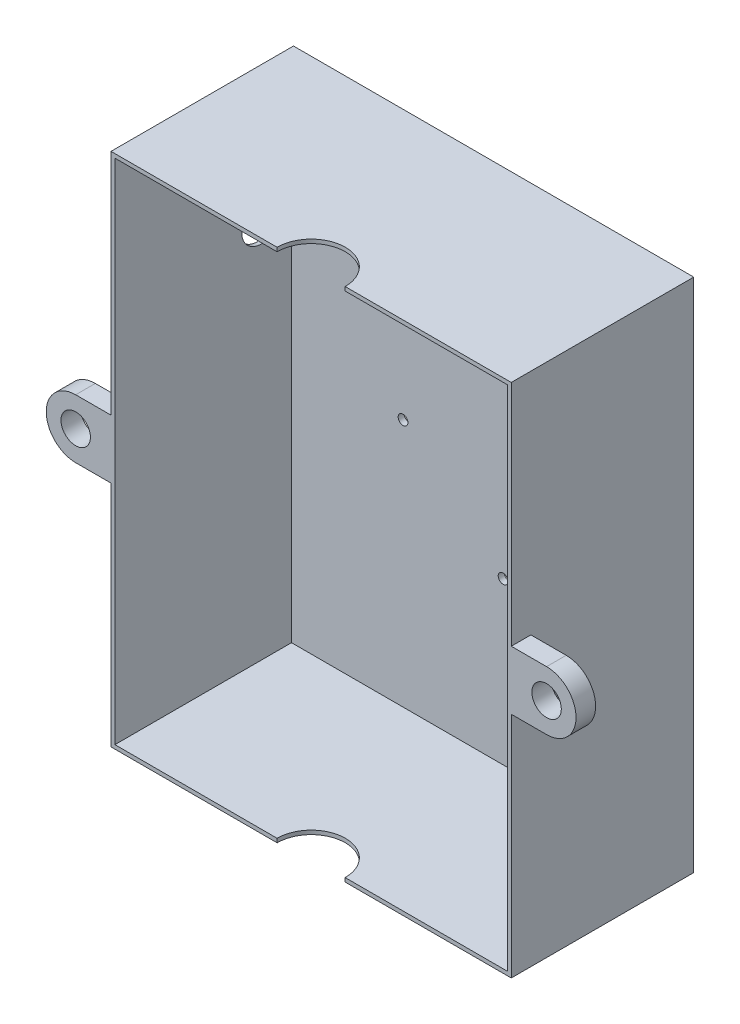
from build123d import *

# Parameters (mm, degrees)
SKETCH1_W                = 200
SKETCH1_H                = 258.87959476
BOSS_EXTRUDE1_DEPTH      = 3
SKETCH2_W                = 200
SKETCH2_H                = 258.87959476
BOSS_EXTRUDE3_DEPTH      = 90
BOSS_EXTRUDE3_DEPTH_BACK = 3
SKETCH3_R                = 2.5
CUT_EXTRUDE2_DEPTH       = 3
SKETCH4_R                = 17.332315934
CUT_EXTRUDE4_DEPTH       = 263.87959476
SKETCH5_R                = 7.5
BOSS_EXTRUDE5_DEPTH      = 10
CUT_EXTRUDE5_REACH       = 239
SKETCH6_R                = 10


with BuildPart() as part:
    # Sketch1 → Boss-Extrude1 (new body)
    with BuildSketch(Plane(origin=(0, 0, 0), x_dir=(-1, 0, 0), z_dir=(0, 0, 1))):
        with Locations((-1.649083583, 6.704740248)):
            Rectangle(SKETCH1_W, SKETCH1_H)
    extrude(amount=BOSS_EXTRUDE1_DEPTH)

    # Sketch2 → Boss-Extrude3 (add, two sides)
    with BuildSketch(Plane.XY.offset(3)) as boss_extrude3_sk:
        Polygon((-100.350916417, 122.735057132), (-100.350916417, -138.144537628), (103.649083583, -138.144537628), (103.649083583, 124.735057132), (-100.350916417, 124.735057132), align=None)
        with Locations((1.649083583, -6.704740248)):
            Rectangle(SKETCH2_W, SKETCH2_H, mode=Mode.SUBTRACT)
    extrude(amount=BOSS_EXTRUDE3_DEPTH)
    extrude(boss_extrude3_sk.sketch, amount=-BOSS_EXTRUDE3_DEPTH_BACK)

    # Sketch3 → Cut-Extrude2 (cut)
    with BuildSketch(Plane(origin=(0, 0, 0), x_dir=(-1, 0, 0), z_dir=(0, 0, -1))):
        with Locations((41.514444489, -9.336870594)):
            Circle(SKETCH3_R)
        with Locations((-9.485555511, 35.263129406)):
            Circle(SKETCH3_R)
        with Locations((-9.485555511, -53.936870594)):
            Circle(SKETCH3_R)
        with Locations((-46.985555511, -20.636870594)):
            Circle(SKETCH3_R)
    extrude(amount=-CUT_EXTRUDE2_DEPTH, mode=Mode.SUBTRACT)

    # Sketch4 → Cut-Extrude4 (cut, through all)
    with BuildSketch(Plane.XZ.offset(138.144537628)):
        with Locations((1.649062898, 92.934091246)):
            Circle(SKETCH4_R)
    extrude(amount=-CUT_EXTRUDE4_DEPTH, mode=Mode.SUBTRACT)

    # Sketch5 → Boss-Extrude5 (add)
    with BuildSketch(Plane.XY.offset(93)):
        with BuildLine():
            Line((103.649083583, 8.295259752), (103.649083583, -6.704740248))
            Line((103.649083583, -6.704740248), (103.649083583, -21.704740248))
            Line((103.649083583, -21.704740248), (121.649083583, -21.704740248))
            ThreePointArc((121.649083583, -21.704740248), (136.649083583, -6.704740248), (121.649083583, 8.295259752))
            Line((121.649083583, 8.295259752), (103.649083583, 8.295259752))
        make_face()
        with Locations((121.649083583, -6.704740248)):
            Circle(SKETCH5_R, mode=Mode.SUBTRACT)
        with BuildLine():
            Line((-100.350916417, -21.704740248), (-100.350916417, -6.704740248))
            Line((-100.350916417, -6.704740248), (-100.350916417, 8.295259752))
            Line((-100.350916417, 8.295259752), (-118.350916417, 8.295259752))
            ThreePointArc((-118.350916417, 8.295259752), (-133.350916417, -6.704740248), (-118.350916417, -21.704740248))
            Line((-118.350916417, -21.704740248), (-100.350916417, -21.704740248))
        make_face()
        with Locations((-118.350916417, -6.704740248)):
            Circle(SKETCH5_R, mode=Mode.SUBTRACT)
    extrude(amount=-BOSS_EXTRUDE5_DEPTH)

    # Sketch6 → Cut-Extrude5 (cut, up to next)
    with BuildSketch(Plane.ZY.offset(100.350916417), mode=Mode.PRIVATE) as cut_extrude5_sk1:
        with Locations((18.364873633, 57.542228563)):
            Circle(SKETCH6_R)
    cut_extrude5_tool1 = extrude(cut_extrude5_sk1.sketch, amount=-CUT_EXTRUDE5_REACH, mode=Mode.PRIVATE) & part.part
    add(cut_extrude5_tool1.solids().sort_by_distance((-100.350916, 57.542229, 18.364874))[0], mode=Mode.SUBTRACT)


solid = part.part
